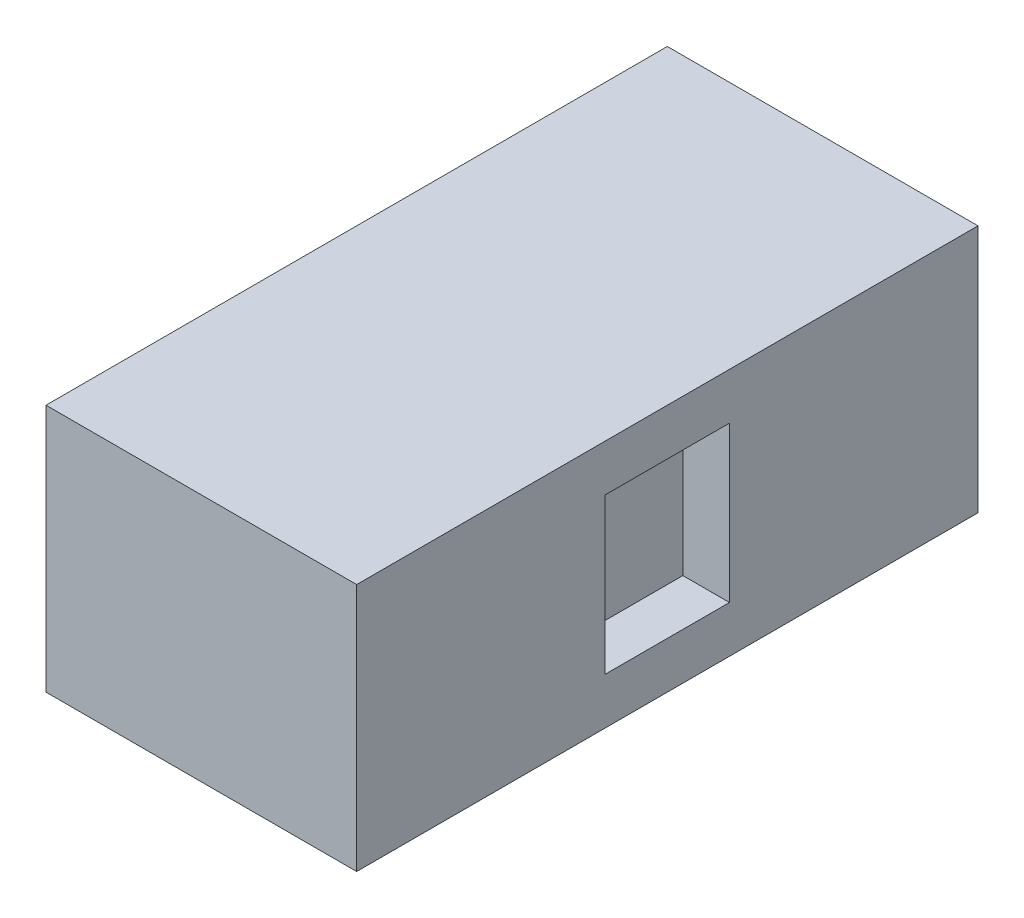
from build123d import *

# Parameters (mm, degrees)
SKETCH1_W           = 20
SKETCH1_H           = 40
BOSS_EXTRUDE1_DEPTH = 3
BOSS_EXTRUDE2_DEPTH = 10
SKETCH4_W           = 20
SKETCH4_H           = 40
BOSS_EXTRUDE3_DEPTH = 3


with BuildPart() as part:
    # Sketch1 → Boss-Extrude1 (new body)
    with BuildSketch(Plane(origin=(0, 0, 0), x_dir=(1, 0, 0), z_dir=(0, 1, 0))):
        Rectangle(SKETCH1_W, SKETCH1_H)
    extrude(amount=BOSS_EXTRUDE1_DEPTH)

    # Sketch2 → Boss-Extrude2 (add)
    with BuildSketch(Plane(origin=(0, 3, 0), x_dir=(1, 0, 0), z_dir=(0, 1, 0))):
        Polygon((-10, -20), (10, -20), (10, -4), (7, -4), (7, 0), (7, 4), (10, 4), (10, 20), (-10, 20), align=None)
    extrude(amount=BOSS_EXTRUDE2_DEPTH)

    # Sketch4 → Boss-Extrude3 (add)
    with BuildSketch(Plane(origin=(0, 13, 0), x_dir=(1, 0, 0), z_dir=(0, 1, 0))):
        Rectangle(SKETCH4_W, SKETCH4_H)
    extrude(amount=BOSS_EXTRUDE3_DEPTH)


solid = part.part
